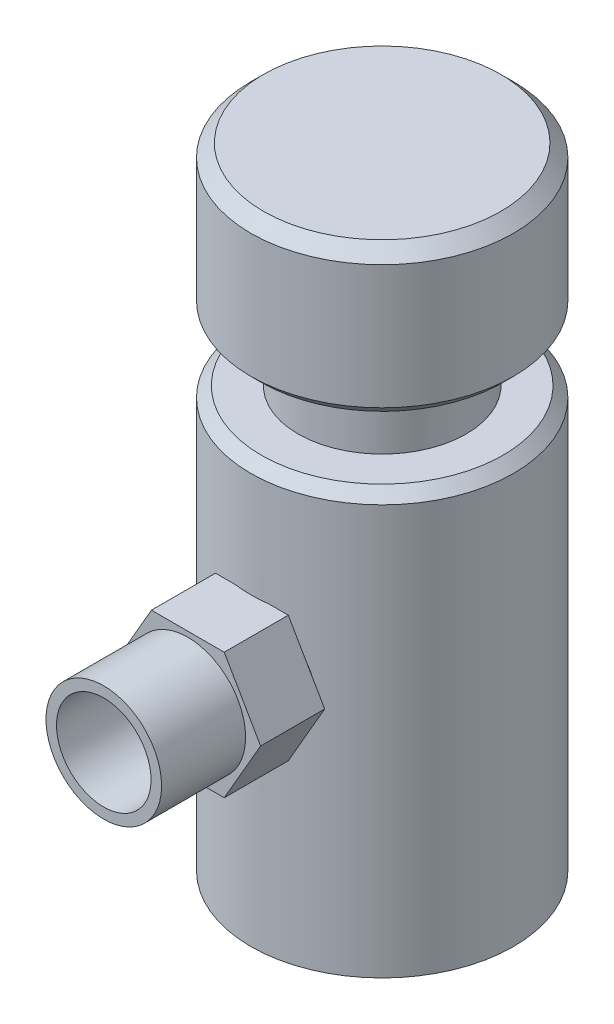
from build123d import *

# Parameters (mm, degrees)
M20X2_0_TAPPED_HOLE1_D     = 18
M20X2_0_TAPPED_HOLE1_DEPTH = 16
M20X2_0_TAPPED_HOLE1_TIP   = 5.407745571
CUT_EXTRUDE1_START         = 12.5
SKETCH5_R                  = 5
CUT_EXTRUDE1_DEPTH         = 10
SKETCH6_R                  = 5
BOSS_EXTRUDE1_DEPTH        = 2
BOSS_EXTRUDE2_DEPTH        = 6
BOSS_EXTRUDE2_DEPTH_BACK   = 0.1
SKETCH8_R                  = 5.5
BOSS_EXTRUDE3_DEPTH        = 8
SKETCH9_R                  = 4.5
CUT_EXTRUDE2_DEPTH         = 25


with BuildPart() as part:
    # Sketch1 → Revolve1 (revolve)
    with BuildSketch(Plane.XY):
        Polygon((0, -44.774695914), (12.5, -44.774695914), (12.5, -5.774695914), (11.5, -4.774695914), (8, -4.774695914), (8, 1.225304086), (11.5, 1.225304086), (12.5, 2.225304086), (12.5, 14.020232183), (11.294928097, 15.225304086), (0, 15.225304086), align=None)
    revolve(axis=Axis((0, 17.675111153, 0), (0, -1, 0)))

    # M20x2.0 Tapped Hole1
    with Locations(Plane(origin=(0, -44.774695914, 0), x_dir=(-1, 0, 0), z_dir=(0, -1, 0))):
        with Locations((0, 0)):
            Hole(M20X2_0_TAPPED_HOLE1_D / 2, depth=M20X2_0_TAPPED_HOLE1_DEPTH)
            with Locations((0, 0, -(M20X2_0_TAPPED_HOLE1_DEPTH + M20X2_0_TAPPED_HOLE1_TIP / 2))):  # 118° drill point
                Cone(0, M20X2_0_TAPPED_HOLE1_D / 2, M20X2_0_TAPPED_HOLE1_TIP, mode=Mode.SUBTRACT)

    # Sketch5 → Cut-Extrude1 (cut)
    with BuildSketch(Plane.XY.offset(CUT_EXTRUDE1_START)):
        with Locations((0, -21.774695914)):
            Circle(SKETCH5_R)
    extrude(amount=-CUT_EXTRUDE1_DEPTH, mode=Mode.SUBTRACT)

    # Sketch6 → Boss-Extrude1 (add)
    with BuildSketch(Plane.XY.offset(12.5)):
        with Locations((0, -21.774695914)):
            Circle(SKETCH6_R)
    extrude(amount=-BOSS_EXTRUDE1_DEPTH)


with BuildPart() as body_2:
    # Sketch7 → Boss-Extrude2 (new body, two sides)
    with BuildSketch(Plane.XY.offset(12.5)) as boss_extrude2_sk:
        Polygon((6.92820323, -21.774695914), (3.464101615, -15.774695914), (-3.464101615, -15.774695914), (-6.92820323, -21.774695914), (-3.464101615, -27.774695914), (3.464101615, -27.774695914), align=None)
    extrude(amount=BOSS_EXTRUDE2_DEPTH)
    extrude(boss_extrude2_sk.sketch, amount=-BOSS_EXTRUDE2_DEPTH_BACK)

    # Sketch8 → Boss-Extrude3 (add)
    with BuildSketch(Plane.XY.offset(18.5)):
        with Locations((0, -21.774695914)):
            Circle(SKETCH8_R)
    extrude(amount=BOSS_EXTRUDE3_DEPTH)


with BuildPart() as cut_extrude2_tool:
    # Sketch9 → Cut-Extrude2 (new body)
    with BuildSketch(Plane.XY.offset(26.5)):
        with Locations((0, -21.774695914)):
            Circle(SKETCH9_R)
    extrude(amount=-CUT_EXTRUDE2_DEPTH)


with BuildPart() as part_1:
    add(part.part)

    # Cut-Extrude2: cut by cut_extrude2_tool
    add(cut_extrude2_tool.part, mode=Mode.SUBTRACT)


with BuildPart() as body_2_1:
    add(body_2.part)

    # Cut-Extrude2: cut by cut_extrude2_tool
    add(cut_extrude2_tool.part, mode=Mode.SUBTRACT)


solid = Compound([part_1.part, body_2_1.part])
